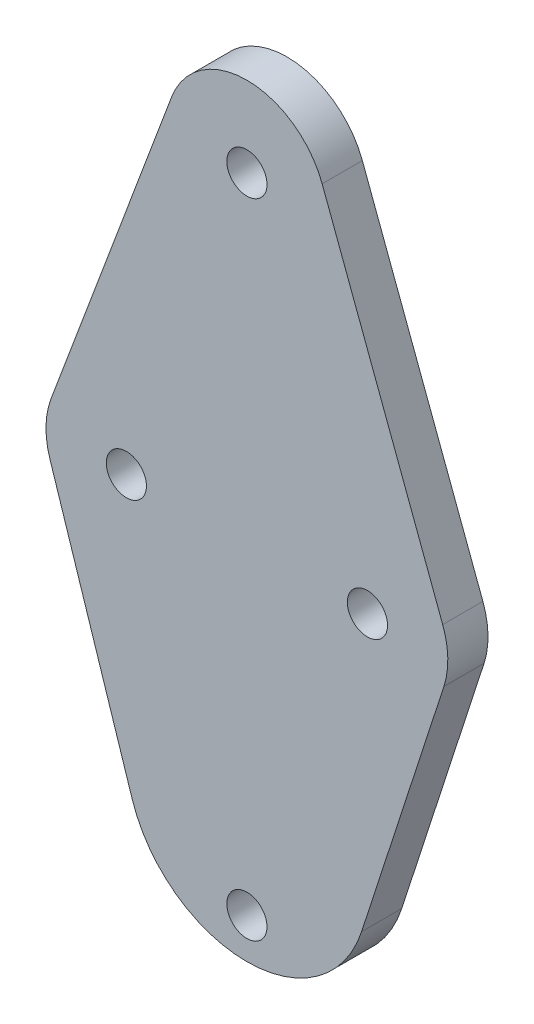
from build123d import *

# Parameters (mm, degrees)
BOSS_EXTRUDE1_DEPTH = 5
SKETCH2_R           = 2.5
CUT_EXTRUDE1_DEPTH  = 6


with BuildPart() as part:
    # Sketch1 → Boss-Extrude1 (new body)
    with BuildSketch(Plane.XY):
        with BuildLine():
            Line((24.363291776, 3.511234416), (9.363291776, 43.511234416))
            ThreePointArc((9.363291776, 43.511234416), (0, 50), (-9.363291776, 43.511234416))
            Line((-9.363291776, 43.511234416), (-24.363291776, 3.511234416))
            ThreePointArc((-24.363291776, 3.511234416), (-24.997496681, 0.223741181), (-24.510999441, -3.088833054))
            Line((-24.510999441, -3.088833054), (-14.266499161, -34.633249581))
            ThreePointArc((-14.266499161, -34.633249581), (0, -45), (14.266499161, -34.633249581))
            Line((14.266499161, -34.633249581), (24.510999441, -3.088833054))
            ThreePointArc((24.510999441, -3.088833054), (24.997496681, 0.223741181), (24.363291776, 3.511234416))
        make_face()
    extrude(amount=BOSS_EXTRUDE1_DEPTH)

    # Sketch2 → Cut-Extrude1 (cut, through all)
    with BuildSketch(Plane.XY.offset(5)):
        with Locations((0, 40)):
            Circle(SKETCH2_R)
        with Locations((0, -40)):
            Circle(SKETCH2_R)
        with Locations((15, 0)):
            Circle(SKETCH2_R)
        with Locations((-15, 0)):
            Circle(SKETCH2_R)
    extrude(amount=-CUT_EXTRUDE1_DEPTH, mode=Mode.SUBTRACT)


solid = part.part
